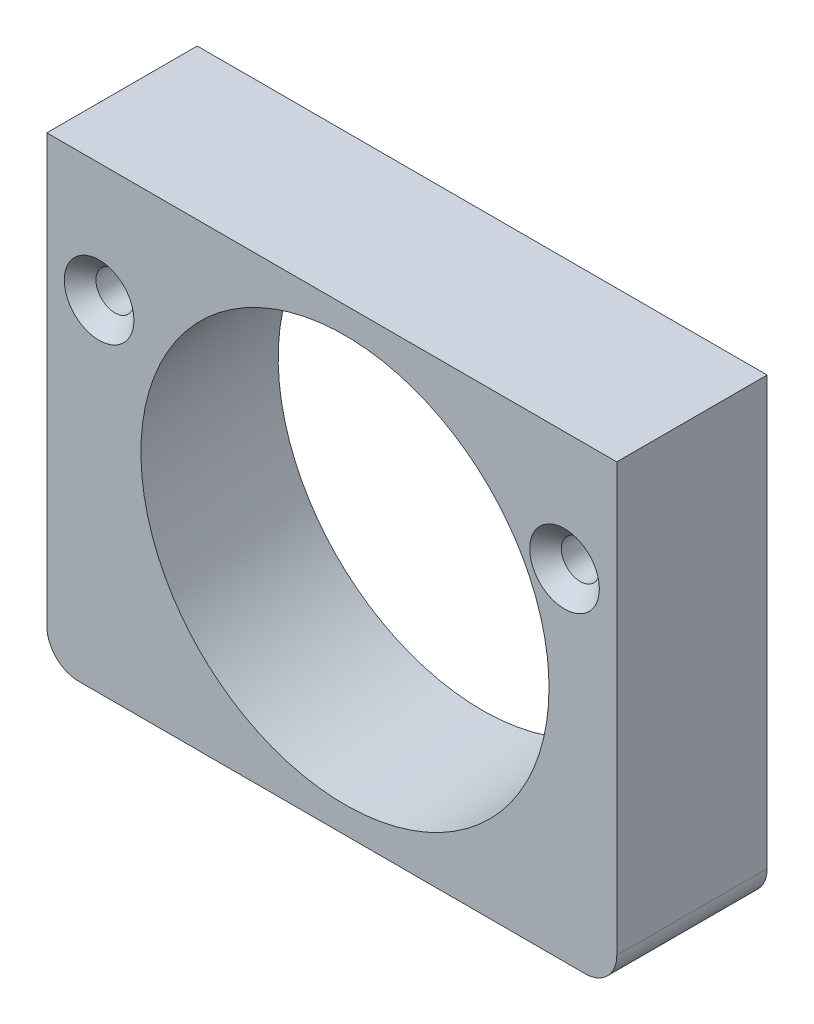
from build123d import *

# Parameters (mm, degrees)
BOSS_EXTRUDE1_DEPTH                                 = 9.5
CUT_EXTRUDE1_REACH                                  = 14.601
SKETCH2_R                                           = 12.8397
CSK_FOR_M2_COUNTERSUNK_FLAT_HEAD_SCREW1_D           = 2.4
CSK_FOR_M2_COUNTERSUNK_FLAT_HEAD_SCREW1_DEPTH       = 9.5
CSK_FOR_M2_COUNTERSUNK_FLAT_HEAD_SCREW1_CSINK_D     = 4.4
CSK_FOR_M2_COUNTERSUNK_FLAT_HEAD_SCREW1_CSINK_ANGLE = 90


with BuildPart() as part:
    # Sketch1 → Boss-Extrude1 (new body)
    with BuildSketch(Plane.XY):
        with BuildLine():
            Line((-16, -14.5), (16, -14.5))
            ThreePointArc((16, -14.5), (17.414213562, -13.914213562), (18, -12.5))
            Line((18, -12.5), (18, 14.5))
            Line((18, 14.5), (-18, 14.5))
            Line((-18, 14.5), (-18, -12.5))
            ThreePointArc((-18, -12.5), (-17.414213562, -13.914213562), (-16, -14.5))
        make_face()
    extrude(amount=BOSS_EXTRUDE1_DEPTH)

    # Sketch2 → Cut-Extrude1 (cut, up to next)
    with BuildSketch(Plane(origin=(0.961559067, 0, 10.990670426), x_dir=(0, 1, 0), z_dir=(0.087155743, 0, 0.996194698)), mode=Mode.PRIVATE) as cut_extrude1_sk1:
        Circle(SKETCH2_R)
    cut_extrude1_tool1 = extrude(cut_extrude1_sk1.sketch, amount=-CUT_EXTRUDE1_REACH, mode=Mode.PRIVATE) & part.part
    add(cut_extrude1_tool1.solids().sort_by_distance((0.961559, 0, 10.99067))[0], mode=Mode.SUBTRACT)

    # CSK for M2 Countersunk Flat Head Screw1
    with Locations(Plane.XY.offset(9.5)):
        with Locations((-14.7, 7), (14.7, 7)):
            CounterSinkHole(CSK_FOR_M2_COUNTERSUNK_FLAT_HEAD_SCREW1_D / 2, CSK_FOR_M2_COUNTERSUNK_FLAT_HEAD_SCREW1_CSINK_D / 2, depth=CSK_FOR_M2_COUNTERSUNK_FLAT_HEAD_SCREW1_DEPTH, counter_sink_angle=CSK_FOR_M2_COUNTERSUNK_FLAT_HEAD_SCREW1_CSINK_ANGLE)


solid = part.part
